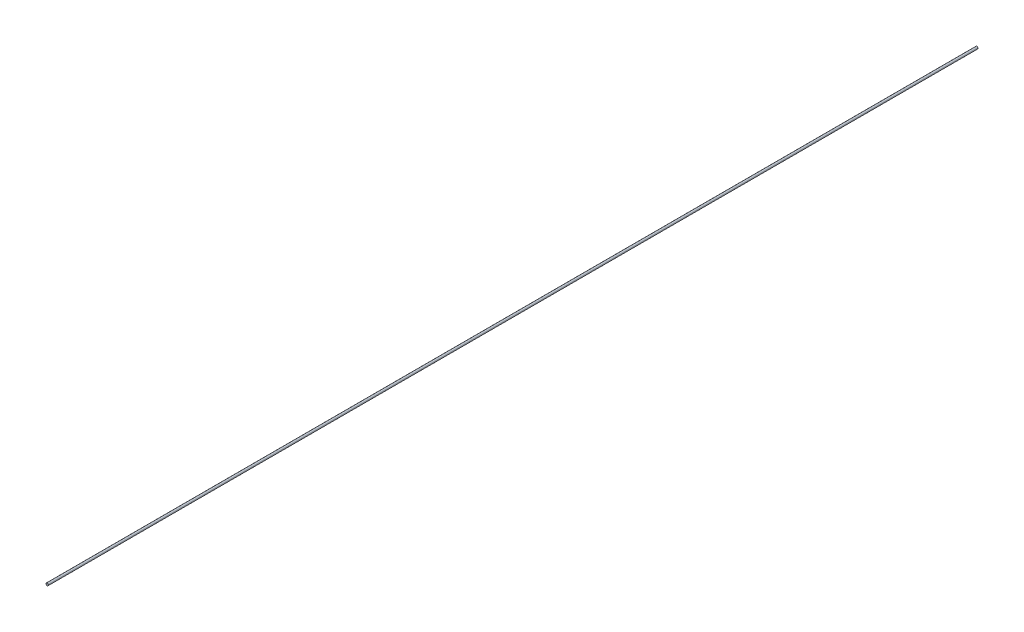
from build123d import *

# Parameters (mm, degrees)
SKETCH1_R           = 0.25
BOSS_EXTRUDE1_DEPTH = 101.7


with BuildPart() as part:
    # Sketch1 → Boss-Extrude1 (new body, symmetric)
    with BuildSketch(Plane.XY):
        Circle(SKETCH1_R)
    extrude(amount=BOSS_EXTRUDE1_DEPTH, both=True)


solid = part.part
